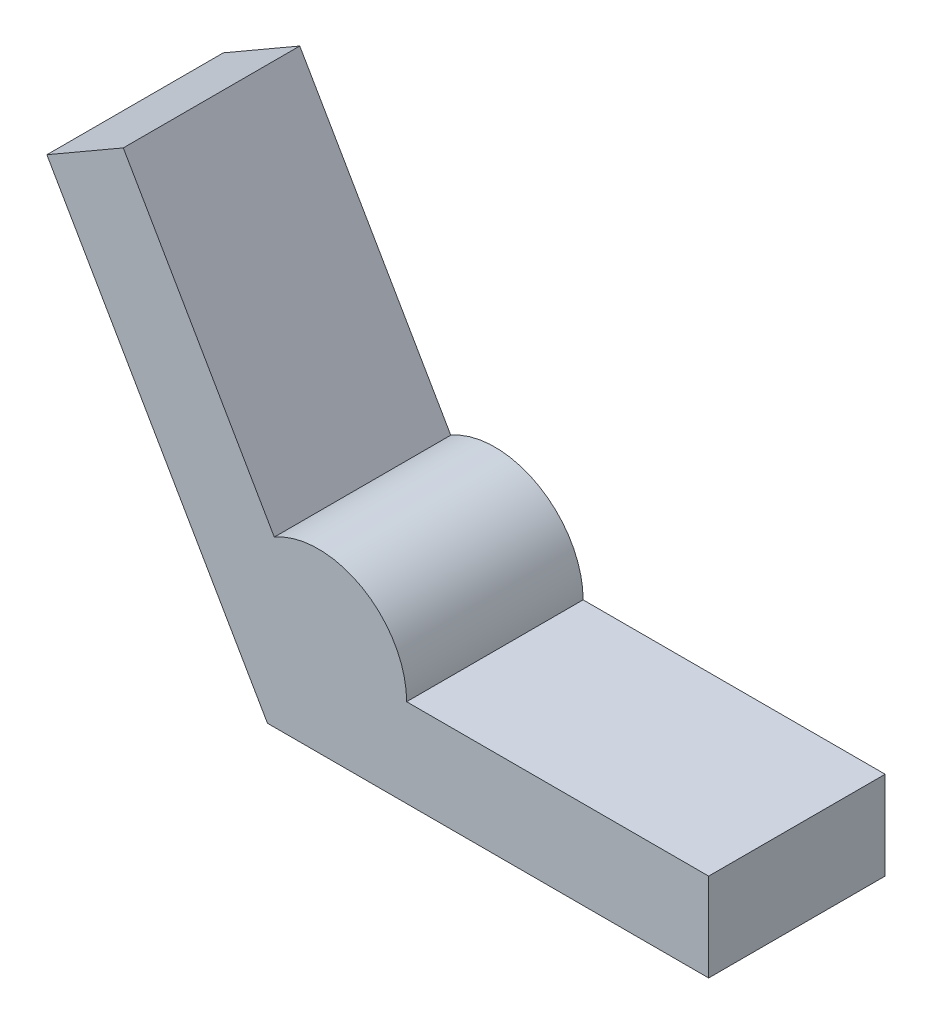
from build123d import *

# Parameters (mm, degrees)
BOSS_EXTRUDE1_DEPTH = 6


with BuildPart() as part:
    # Sketch1 → Boss-Extrude1 (new body)
    with BuildSketch(Plane.XY):
        with BuildLine():
            Line((0, 0), (15, 0))
            Line((15, 0), (15, 3))
            Line((15, 3), (4.732050808, 3))
            ThreePointArc((4.732050808, 3), (3.232050808, 5.598076211), (0.232050808, 5.598076211))
            Line((0.232050808, 5.598076211), (-4.901923789, 14.490381057))
            Line((-4.901923789, 14.490381057), (-7.5, 12.990381057))
            Line((-7.5, 12.990381057), (0, 0))
        make_face()
    extrude(amount=BOSS_EXTRUDE1_DEPTH)


solid = part.part
